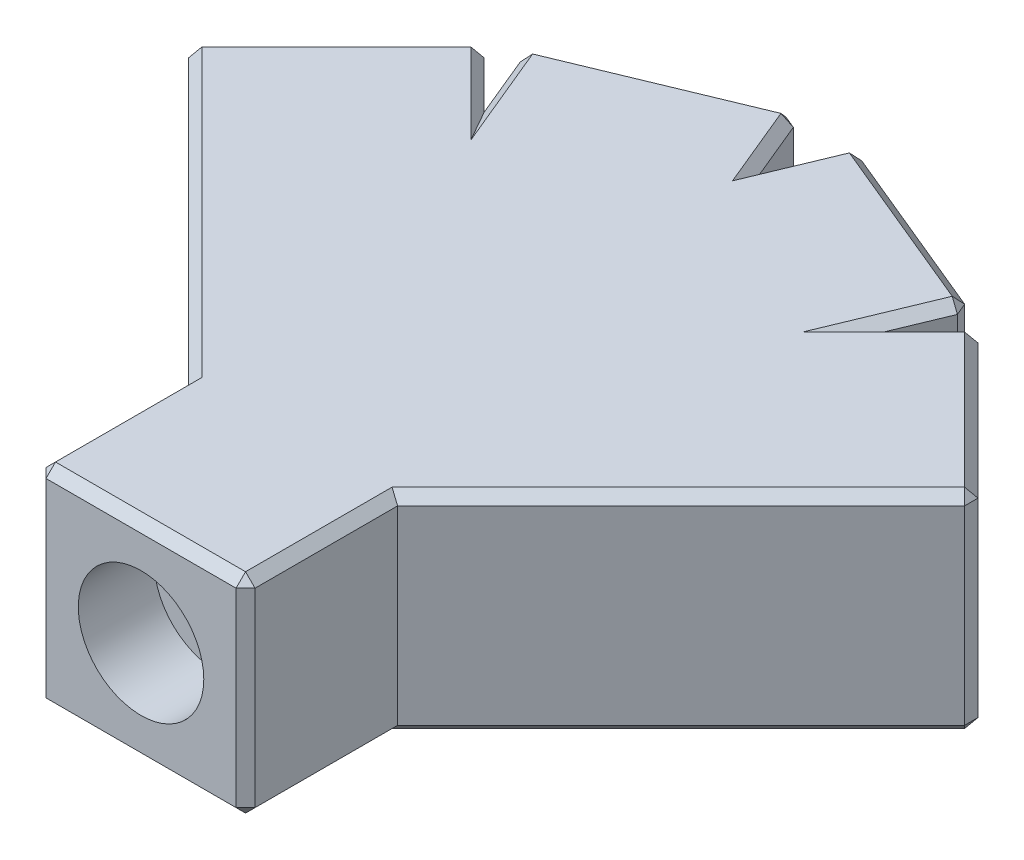
from build123d import *

# Parameters (mm, degrees)
BOSS_EXTRUDE1_DEPTH = 11
SKETCH5_R           = 1.25
CUT_EXTRUDE3_DEPTH  = 21
SKETCH6_R           = 1.25
CUT_EXTRUDE4_DEPTH  = 14
SKETCH7_R           = 1.25
CUT_EXTRUDE5_DEPTH  = 14
SKETCH8_R           = 1.25
CUT_EXTRUDE6_DEPTH  = 21
SKETCH9_W           = 11
SKETCH9_H           = 11
BOSS_EXTRUDE2_DEPTH = 8
SKETCH10_R          = 1.25
CUT_EXTRUDE7_DEPTH  = 18
SKETCH12_R          = 3.302
CUT_EXTRUDE9_DEPTH  = 4
SKETCH18_W          = 11
SKETCH18_H          = 11
SKETCH18_R          = 3.302
BOSS_EXTRUDE3_DEPTH = 4
SKETCH19_W          = 11
SKETCH19_H          = 11
SKETCH19_R          = 3.302
BOSS_EXTRUDE4_DEPTH = 4
SKETCH20_W          = 11
SKETCH20_H          = 11
SKETCH20_R          = 3.302
BOSS_EXTRUDE5_DEPTH = 4
SKETCH22_W          = 11
SKETCH22_H          = 11
SKETCH22_R          = 3.302
BOSS_EXTRUDE7_DEPTH = 4
CHAMFER1_SIZE       = 0.5


with BuildPart() as part:
    # Sketch2 → Boss-Extrude1 (new body)
    with BuildSketch(Plane(origin=(0, 0, 0), x_dir=(1, 0, 0), z_dir=(0, 1, 0))):
        Polygon((0, 24.4285418), (-10.162674858, 20.219024044), (-17.940849451, 12.440849451), (-5.5, 0), (5.5, 0), (17.940849451, 12.440849451), (10.162674858, 20.219024044), align=None)
    extrude(amount=BOSS_EXTRUDE1_DEPTH)

    # Sketch5 → Cut-Extrude3 (cut)
    with BuildSketch(Plane(origin=(15.190849451, 0, -15.190849451), x_dir=(-0.707106781, 0, -0.707106781), z_dir=(0.707106781, 0, -0.707106781))):
        with Locations((1.610912703, 5.5)):
            Circle(SKETCH5_R)
    extrude(amount=-CUT_EXTRUDE3_DEPTH, mode=Mode.SUBTRACT)

    # Sketch6 → Cut-Extrude4 (cut)
    with BuildSketch(Plane(origin=(8.636793781, 0, -20.85106468), x_dir=(-0.923879533, 0, -0.382683432), z_dir=(0.382683432, 0, -0.923879533))):
        with Locations((3.848398224, 5.5)):
            Circle(SKETCH6_R)
    extrude(amount=-CUT_EXTRUDE4_DEPTH, mode=Mode.SUBTRACT)

    # Sketch7 → Cut-Extrude5 (cut)
    with BuildSketch(Plane(origin=(-8.636793781, 0, -20.85106468), x_dir=(-0.923879533, 0, 0.382683432), z_dir=(-0.382683432, 0, -0.923879533))):
        with Locations((-3.848398224, 5.5)):
            Circle(SKETCH7_R)
    extrude(amount=-CUT_EXTRUDE5_DEPTH, mode=Mode.SUBTRACT)

    # Sketch8 → Cut-Extrude6 (cut)
    with BuildSketch(Plane(origin=(-15.190849451, 0, -15.190849451), x_dir=(-0.707106781, 0, 0.707106781), z_dir=(-0.707106781, 0, -0.707106781))):
        with Locations((-1.610912703, 5.5)):
            Circle(SKETCH8_R)
    extrude(amount=-CUT_EXTRUDE6_DEPTH, mode=Mode.SUBTRACT)

    # Sketch9 → Boss-Extrude2 (add)
    with BuildSketch(Plane.XY):
        with Locations((0, 5.5)):
            Rectangle(SKETCH9_W, SKETCH9_H)
    extrude(amount=BOSS_EXTRUDE2_DEPTH)

    # Sketch10 → Cut-Extrude7 (cut)
    with BuildSketch(Plane.XY.offset(8)):
        with Locations((0, 5.5)):
            Circle(SKETCH10_R)
    extrude(amount=-CUT_EXTRUDE7_DEPTH, mode=Mode.SUBTRACT)

    # Sketch12 → Cut-Extrude9 (cut)
    with BuildSketch(Plane.XY.offset(8)):
        with Locations((0, 5.5)):
            Circle(SKETCH12_R)
    extrude(amount=-CUT_EXTRUDE9_DEPTH, mode=Mode.SUBTRACT)

    # Sketch18 → Boss-Extrude3 (add)
    with BuildSketch(Plane(origin=(15.190849451, 0, -15.190849451), x_dir=(-0.707106781, 0, -0.707106781), z_dir=(0.707106781, 0, -0.707106781))):
        with Locations((1.610912703, 5.5)):
            Rectangle(SKETCH18_W, SKETCH18_H)
        with Locations((1.610912703, 5.5)):
            Circle(SKETCH18_R, mode=Mode.SUBTRACT)
    extrude(amount=BOSS_EXTRUDE3_DEPTH)

    # Sketch19 → Boss-Extrude4 (add)
    with BuildSketch(Plane(origin=(8.636793781, 0, -20.85106468), x_dir=(-0.923879533, 0, -0.382683432), z_dir=(0.382683432, 0, -0.923879533))):
        with Locations((3.848398224, 5.5)):
            Rectangle(SKETCH19_W, SKETCH19_H)
        with Locations((3.848398224, 5.5)):
            Circle(SKETCH19_R, mode=Mode.SUBTRACT)
    extrude(amount=BOSS_EXTRUDE4_DEPTH)

    # Sketch20 → Boss-Extrude5 (add)
    with BuildSketch(Plane(origin=(-8.636793781, 0, -20.85106468), x_dir=(-0.923879533, 0, 0.382683432), z_dir=(-0.382683432, 0, -0.923879533))):
        with Locations((-3.848398224, 5.5)):
            Rectangle(SKETCH20_W, SKETCH20_H)
        with Locations((-3.848398224, 5.5)):
            Circle(SKETCH20_R, mode=Mode.SUBTRACT)
    extrude(amount=BOSS_EXTRUDE5_DEPTH)

    # Sketch22 → Boss-Extrude7 (add)
    with BuildSketch(Plane(origin=(-15.190849451, 0, -15.190849451), x_dir=(-0.707106781, 0, 0.707106781), z_dir=(-0.707106781, 0, -0.707106781))):
        with Locations((-1.610912703, 5.5)):
            Rectangle(SKETCH22_W, SKETCH22_H)
        with Locations((-1.610912703, 5.5)):
            Circle(SKETCH22_R, mode=Mode.SUBTRACT)
    extrude(amount=BOSS_EXTRUDE7_DEPTH)

    # Chamfer1
    chamfer1_edges = [part.edges().sort_by_distance(p)[0] for p in [
        (16.880189279, 0, -19.158363872),
        (20.769276575, 5.5, -15.269276575),
        (12.991101982, 5.5, -23.047451168),
        (11.57688842, 0, -21.633237606),
        (16.880189279, 11, -19.158363872),
        (11.57688842, 11, -21.633237606),
        (11.693408587, 5.5, -23.914542174),
        (6.612071158, 0, -26.019301052),
        (1.530733729, 5.5, -28.12405993),
        (6.612071158, 11, -26.019301052),
        (10.928041722, 11, -22.066783109),
        (10.928041722, 0, -22.066783109),
        (0.765366865, 0, -26.276300865),
        (0.765366865, 11, -26.276300865),
        (-1.530733729, 5.5, -28.12405993),
        (-6.612071158, 0, -26.019301052),
        (-11.693408587, 5.5, -23.914542174),
        (-6.612071158, 11, -26.019301052),
        (-0.765366865, 11, -26.276300865),
        (-0.765366865, 0, -26.276300865),
        (-10.928041722, 0, -22.066783109),
        (-10.928041722, 11, -22.066783109),
        (-13.134638288, 11, -7.634638288),
        (-12.991101982, 5.5, -23.047451168),
        (-16.880189279, 0, -19.158363872),
        (-20.769276575, 5.5, -15.269276575),
        (-16.880189279, 11, -19.158363872),
        (-11.57688842, 11, -21.633237606),
        (-11.57688842, 0, -21.633237606),
        (13.134638288, 11, -7.634638288),
        (-5.5, 11, 4),
        (-5.5, 0, 4),
        (5.5, 0, 4),
        (5.5, 11, 4),
        (-5.5, 5.5, 8),
        (0, 0, 8),
        (5.5, 5.5, 8),
        (13.134638288, 0, -7.634638288),
        (0, 11, 8),
        (-13.134638288, 0, -7.634638288),
    ]]
    chamfer(chamfer1_edges, length=CHAMFER1_SIZE)


solid = part.part
